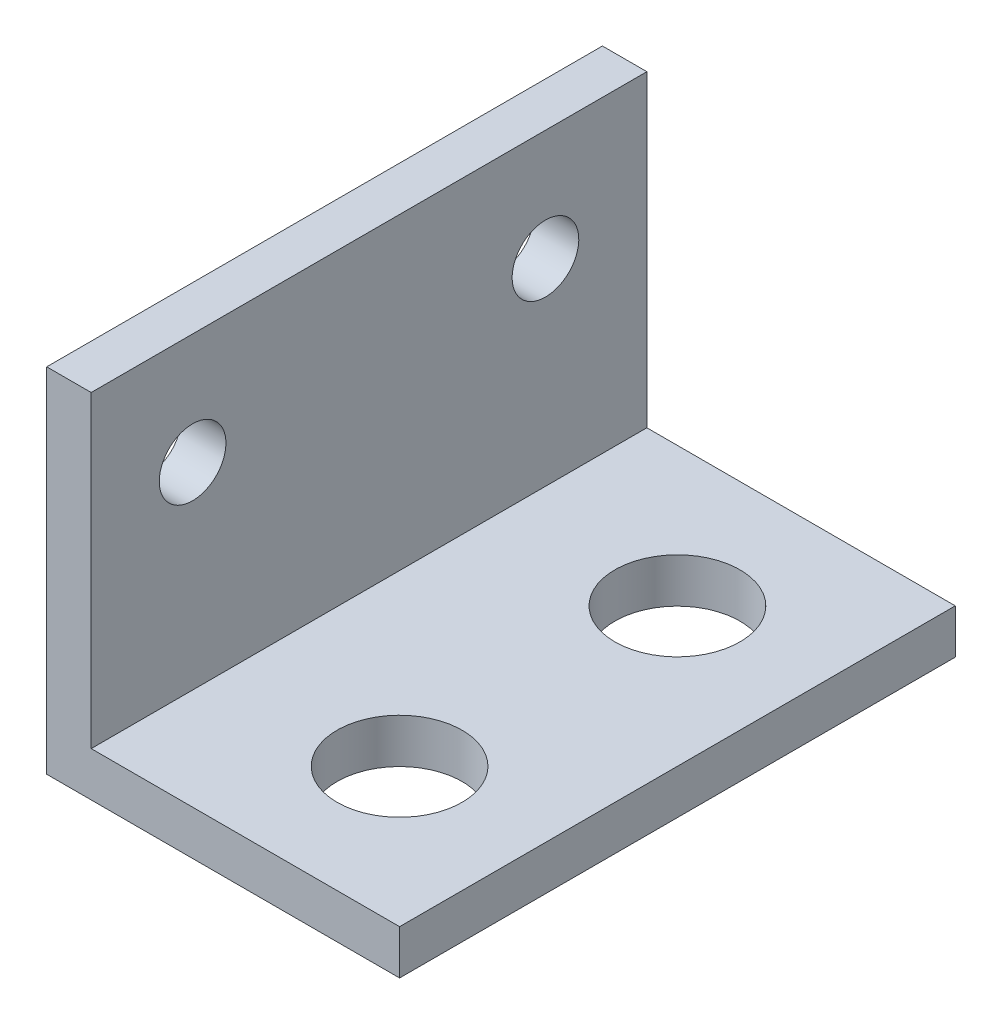
from build123d import *

# Parameters (mm, degrees)
BOSS_EXTRUDE1_DEPTH  = 10
M4_CLEARANCE_HOLE1_D = 4.5
M2_CLEARANCE_HOLE1_D = 2.4


with BuildPart() as part:
    # Sketch1 → Boss-Extrude1 (new body, symmetric)
    with BuildSketch(Plane.XY):
        Polygon((0, 0), (0, 12.7), (1.6002, 12.7), (1.6002, 1.6002), (12.7, 1.6002), (12.7, 0), align=None)
    extrude(amount=BOSS_EXTRUDE1_DEPTH, both=True)

    # M4 Clearance Hole1 (through all)
    with Locations(Plane(origin=(0, 1.6002, 0), x_dir=(1, 0, 0), z_dir=(0, 1, 0))):
        with Locations((7.7, -5), (7.7, 5)):
            Hole(M4_CLEARANCE_HOLE1_D / 2)

    # M2 Clearance Hole1 (through all)
    with Locations(Plane.ZY):
        with Locations((-6.35, 8.7), (6.35, 8.7)):
            Hole(M2_CLEARANCE_HOLE1_D / 2)


solid = part.part
